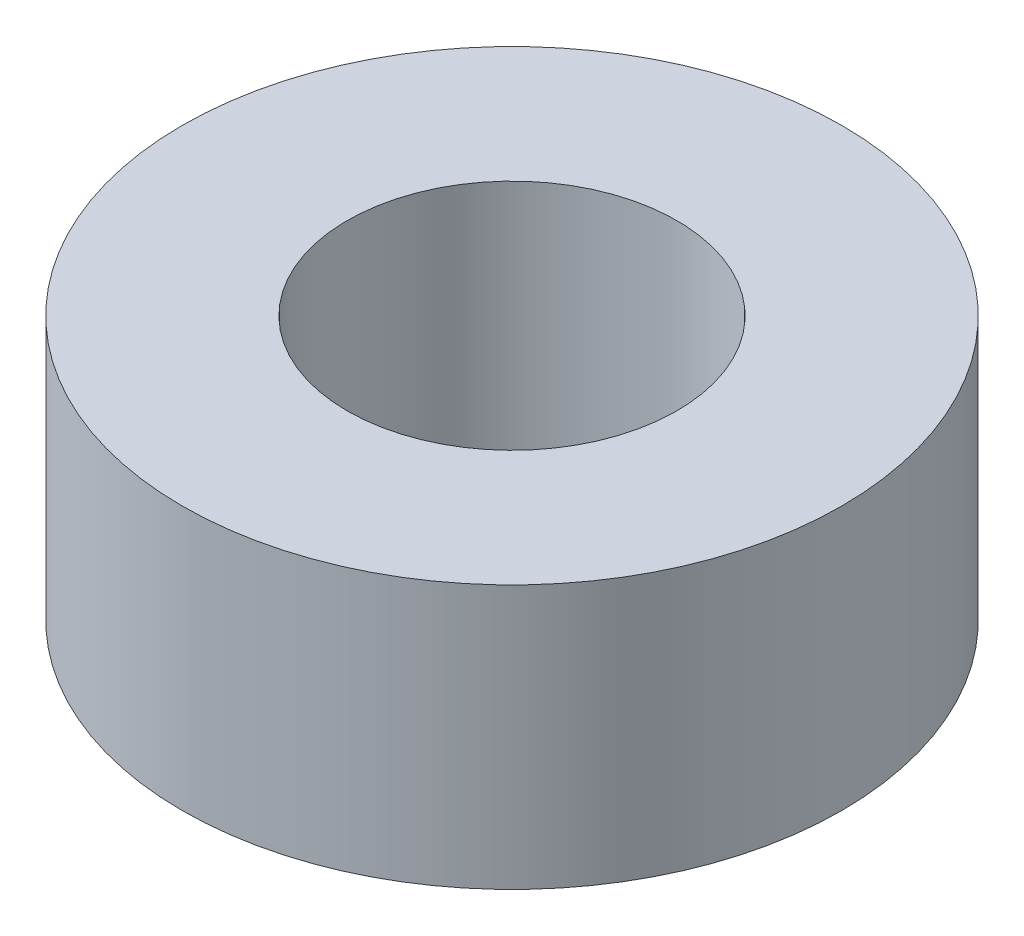
from build123d import *

# Parameters (mm, degrees)
SKETCH_1_R      = 5
SKETCH_1_R_2    = 2.5
EXTRUDE_1_DEPTH = 2


with BuildPart() as part:
    # 草图1 → 凸台-拉伸1 (new body, symmetric)
    with BuildSketch(Plane(origin=(0, 0, 0), x_dir=(1, 0, 0), z_dir=(0, 1, 0))):
        Circle(SKETCH_1_R)
        Circle(SKETCH_1_R_2, mode=Mode.SUBTRACT)
    extrude(amount=EXTRUDE_1_DEPTH, both=True)


solid = part.part
